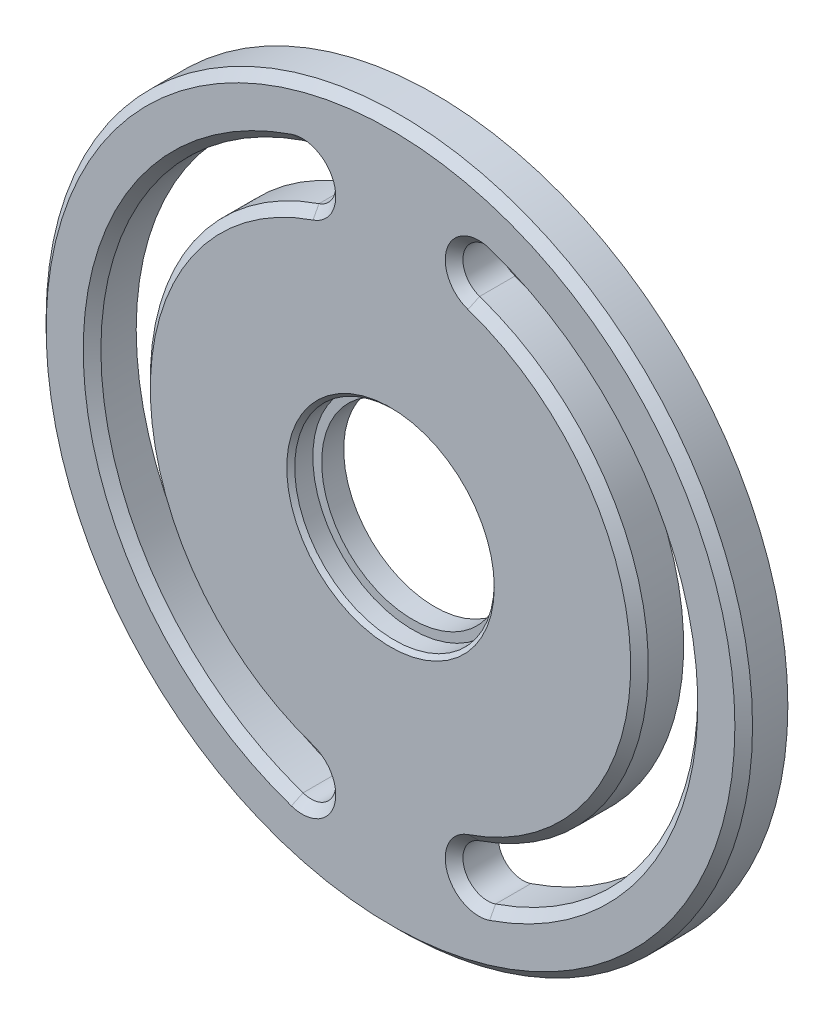
from build123d import *

# Parameters (mm, degrees)
SKETCH1_R           = 50.8
BOSS_EXTRUDE1_DEPTH = 6.35
CHAMFER1_SIZE       = 1.27


with BuildPart() as part:
    # Sketch1 → Boss-Extrude1 (new body)
    with BuildSketch(Plane.XY):
        Circle(SKETCH1_R)
        with BuildLine():
            ThreePointArc((-13.847096774, 40.631261203), (-42.926, 0), (-13.847096774, -40.631261203))
            ThreePointArc((-13.847096774, -40.631261203), (-9.334096705, -38.412454682), (-11.552903226, -33.899454613))
            ThreePointArc((-11.552903226, -33.899454613), (-35.814, 0), (-11.552903226, 33.899454613))
            ThreePointArc((-11.552903226, 33.899454613), (-9.334096705, 38.412454682), (-13.847096774, 40.631261203))
        make_face(mode=Mode.SUBTRACT)
        with BuildLine():
            ThreePointArc((13.847096774, 40.631261203), (42.926, 0), (13.847096774, -40.631261203))
            ThreePointArc((13.847096774, -40.631261203), (9.334096705, -38.412454682), (11.552903226, -33.899454613))
            ThreePointArc((11.552903226, -33.899454613), (35.814, 0), (11.552903226, 33.899454613))
            ThreePointArc((11.552903226, 33.899454613), (9.334096705, 38.412454682), (13.847096774, 40.631261203))
        make_face(mode=Mode.SUBTRACT)
    extrude(amount=BOSS_EXTRUDE1_DEPTH)

    # Chamfer1
    chamfer1_edges = [part.edges().sort_by_distance(p)[0] for p in [
        (-9.334096705, -38.412454682, 6.35),
        (-35.814, 0, 6.35),
        (9.334096705, 38.412454682, 6.35),
        (35.814, 0, 6.35),
        (9.334096705, -38.412454682, 6.35),
        (42.926, 0, 6.35),
        (-50.8, 0, 6.35),
        (-9.334096705, 38.412454682, 6.35),
        (-42.926, 0, 6.35),
    ]]
    chamfer(chamfer1_edges, length=CHAMFER1_SIZE)

    # Sketch5 → CBORE for 1/2 Heavy Hex Bolt1 (revolve, cut)
    with BuildSketch(Plane(origin=(0, 0, 6.35), x_dir=(0, -1, 0), z_dir=(1, 0, 0))):
        Polygon((0, 0), (0, 6.35), (13.081, 6.35), (13.081, 3.175), (14.351, 3.175), (14.351, 0.5715), (14.9225, 0), align=None)
    revolve(axis=Axis((0, 0, 12.7), (0, 0, -1)), mode=Mode.SUBTRACT)


solid = part.part
